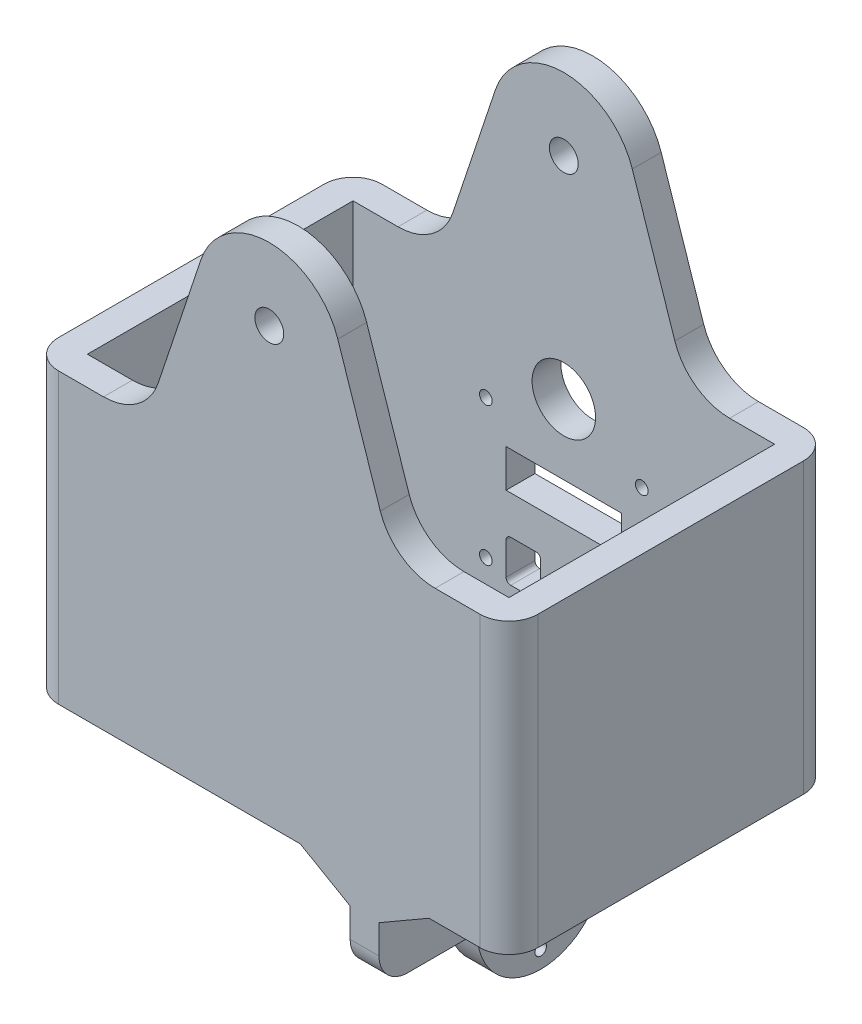
from build123d import *

# Parameters (mm, degrees)
SKETCH3_W             = 32
SKETCH3_H             = 50
BOSS_EXTRUDE1_DEPTH   = 5
CUT_W                 = 20
CUT_H                 = 6.55
CUT_EXTRUDE1_DEPTH    = 10
SKETCH4_W             = 25.5
SKETCH4_H             = 50
BOSS_EXTRUDE2_DEPTH   = 5
SKETCH5_W             = 5
SKETCH5_H             = 50
BOSS_EXTRUDE3_DEPTH   = 51
BOSS_EXTRUDE4_REACH   = 80
SKETCH6_W             = 5
SKETCH6_H             = 50
BOSS_EXTRUDE5_DEPTH   = 5
FILLET1_R             = 10
BOSS_EXTRUDE6_DEPTH   = 5
SKETCH9_W             = 5
SKETCH9_H             = 15
BOSS_EXTRUDE7_DEPTH   = 2.5
BOSS_EXTRUDE8_DEPTH   = 5
SKETCH11_R            = 1
CUT_EXTRUDE2_DEPTH    = 5
FILLET4_R             = 5
FILLET5_R             = 5
CHAMFER1_SIZE         = 5
CHAMFER1_SIZE2        = 8.660254038
CHAMFER1_PART_2_SIZE  = 5
CHAMFER1_PART_2_SIZE2 = 8.660254038
FILLET6_R             = 5
CHAMFER2_SIZE         = 5
CHAMFER2_SIZE2        = 8.660254038
CHAMFER2_PART_2_SIZE  = 5
CHAMFER2_PART_2_SIZE2 = 8.660254038
SKETCH12_R            = 2.5
CUT_EXTRUDE3_DEPTH    = 57


with BuildPart() as part:
    # Sketch3 → Boss-Extrude1 (new body)
    with BuildSketch(Plane(origin=(0, 0, -16), x_dir=(-1, 0, 0), z_dir=(0, 0, -1))):
        with Locations((0, -13.5)):
            Rectangle(SKETCH3_W, SKETCH3_H)
    extrude(amount=BOSS_EXTRUDE1_DEPTH)

    # Cut → Cut-Extrude1 (cut)
    with BuildSketch(Plane(origin=(0, 0, -16), x_dir=(-1, 0, 0), z_dir=(0, 0, -1))):
        with BuildLine():
            Line((9.2, -32.5), (4.8, -32.5))
            ThreePointArc((4.8, -32.5), (4.234314575, -32.265685425), (4, -31.7))
            Line((4, -31.7), (4, -26.1))
            ThreePointArc((4, -26.1), (4.234314575, -25.534314575), (4.8, -25.3))
            Line((4.8, -25.3), (9.2, -25.3))
            ThreePointArc((9.2, -25.3), (9.765685425, -25.534314575), (10, -26.1))
            Line((10, -26.1), (10, -31.7))
            ThreePointArc((10, -31.7), (9.765685425, -32.265685425), (9.2, -32.5))
        make_face()
        with BuildLine():
            Line((-10, -31.7), (-10, -26.1))
            ThreePointArc((-10, -26.1), (-9.765685425, -25.534314575), (-9.2, -25.3))
            Line((-9.2, -25.3), (-4.8, -25.3))
            ThreePointArc((-4.8, -25.3), (-4.234314575, -25.534314575), (-4, -26.1))
            Line((-4, -26.1), (-4, -31.7))
            ThreePointArc((-4, -31.7), (-4.234314575, -32.265685425), (-4.8, -32.5))
            Line((-4.8, -32.5), (-9.2, -32.5))
            ThreePointArc((-9.2, -32.5), (-9.765685425, -32.265685425), (-10, -31.7))
        make_face()
        with Locations((0, -15.375)):
            Rectangle(CUT_W, CUT_H)
        with BuildLine():
            ThreePointArc((-5.5, 0), (0, -5.5), (5.5, 0))
            ThreePointArc((5.5, 0), (0, 5.5), (-5.5, 0))
        make_face()
        with BuildLine():
            ThreePointArc((13.5, -7.6), (14.6, -6.500000002), (13.500000003, -5.4))
            ThreePointArc((13.500000003, -5.4), (12.4, -6.499999998), (13.5, -7.6))
        make_face()
        with BuildLine():
            ThreePointArc((13.5, -31.6), (14.6, -30.500000002), (13.500000003, -29.4))
            ThreePointArc((13.500000003, -29.4), (12.4, -30.499999998), (13.5, -31.6))
        make_face()
        with BuildLine():
            ThreePointArc((-13.5, -31.6), (-12.4, -30.499999998), (-13.500000003, -29.4))
            ThreePointArc((-13.500000003, -29.4), (-14.6, -30.500000002), (-13.5, -31.6))
        make_face()
        with BuildLine():
            ThreePointArc((-13.5, -7.6), (-12.4, -6.499999998), (-13.500000003, -5.4))
            ThreePointArc((-13.500000003, -5.4), (-14.6, -6.500000002), (-13.5, -7.6))
        make_face()
    extrude(amount=CUT_EXTRUDE1_DEPTH, mode=Mode.SUBTRACT)

    # Sketch4 → Boss-Extrude2 (add)
    with BuildSketch(Plane(origin=(0, 0, -21), x_dir=(-1, 0, 0), z_dir=(0, 0, -1))):
        with Locations((-28.75, -13.5)):
            Rectangle(SKETCH4_W, SKETCH4_H)
        with Locations((28.75, -13.5)):
            Rectangle(SKETCH4_W, SKETCH4_H)
    extrude(amount=-BOSS_EXTRUDE2_DEPTH)

    # Sketch5 → Boss-Extrude3 (add)
    with BuildSketch(Plane.XY.offset(-16)):
        with Locations((-39, -13.5)):
            Rectangle(SKETCH5_W, SKETCH5_H)
        with Locations((39, -13.5)):
            Rectangle(SKETCH5_W, SKETCH5_H)
    extrude(amount=BOSS_EXTRUDE3_DEPTH)

    # Sketch6 → Boss-Extrude4 (add, up to next)
    with BuildSketch(Plane.ZY.offset(-36.5), mode=Mode.PRIVATE) as boss_extrude4_sk1:
        with Locations((32.5, -13.5)):
            Rectangle(SKETCH6_W, SKETCH6_H)
    boss_extrude4_tool1 = extrude(boss_extrude4_sk1.sketch, amount=BOSS_EXTRUDE4_REACH, mode=Mode.PRIVATE) - part.part
    add(boss_extrude4_tool1.solids().sort_by_distance((36.5, -13.5, 32.5))[0])

    # Sketch7 → Boss-Extrude5 (add)
    with BuildSketch(Plane(origin=(0, 0, -21), x_dir=(-1, 0, 0), z_dir=(0, 0, -1))):
        with BuildLine():
            Line((-11.859707003, 40.449348023), (-21.5, 11.5))
            Line((-21.5, 11.5), (21.5, 11.5))
            Line((21.5, 11.5), (11.859707003, 40.449348023))
            ThreePointArc((11.859707003, 40.449348023), (0, 49), (-11.859707003, 40.449348023))
        make_face()
    extrude(amount=-BOSS_EXTRUDE5_DEPTH)

    # Fillet1
    fillet1_edges = [part.edges().sort_by_distance(p)[0] for p in [
        (-21.5, 11.5, -18.5),
        (21.5, 11.5, -18.5),
    ]]
    fillet(fillet1_edges, radius=FILLET1_R)

    # Sketch8 → Boss-Extrude6 (add)
    with BuildSketch(Plane.XY.offset(35)):
        with BuildLine():
            Line((11.859707003, 40.449348023), (19.222068481, 18.340521582))
            ThreePointArc((19.222068481, 18.340521582), (22.86153451, 13.388440835), (28.709834084, 11.5))
            Line((28.709834084, 11.5), (-28.709834084, 11.5))
            ThreePointArc((-28.709834084, 11.5), (-22.86153451, 13.388440835), (-19.222068481, 18.340521582))
            Line((-19.222068481, 18.340521582), (-11.859707003, 40.449348023))
            ThreePointArc((-11.859707003, 40.449348023), (0, 49), (11.859707003, 40.449348023))
        make_face()
    extrude(amount=-BOSS_EXTRUDE6_DEPTH)

    # Sketch9 → Boss-Extrude7 (add, symmetric)
    with BuildSketch(Plane(origin=(16.5, 0, 0), x_dir=(0, 0, -1), z_dir=(1, 0, 0))):
        with Locations((-32.5, -46)):
            Rectangle(SKETCH9_W, SKETCH9_H)
        with Locations((18.5, -46)):
            Rectangle(SKETCH9_W, SKETCH9_H)
    extrude(amount=BOSS_EXTRUDE7_DEPTH, both=True)

    # Sketch10 → Boss-Extrude8 (add)
    with BuildSketch(Plane(origin=(19, 0, 0), x_dir=(0, 0, -1), z_dir=(1, 0, 0))):
        with BuildLine():
            Line((-30, -53.5), (-18, -53.5))
            ThreePointArc((-18, -53.5), (-7, -64.5), (4, -53.5))
            Line((4, -53.5), (16, -53.5))
            Line((16, -53.5), (16, -43.5))
            Line((16, -43.5), (-2.417424305, -43.5))
            ThreePointArc((-2.417424305, -43.5), (-7, -42.5), (-11.582575695, -43.5))
            Line((-11.582575695, -43.5), (-30, -43.5))
            Line((-30, -43.5), (-30, -53.5))
        make_face()
    extrude(amount=-BOSS_EXTRUDE8_DEPTH)

    # Sketch11 → Cut-Extrude2 (cut)
    with BuildSketch(Plane(origin=(19, 0, 0), x_dir=(0, 0, -1), z_dir=(1, 0, 0))):
        with Locations((-15, -53.5)):
            Circle(SKETCH11_R)
        with Locations((-7, -45.5)):
            Circle(SKETCH11_R)
        with Locations((1, -53.5)):
            Circle(SKETCH11_R)
        with Locations((-7, -61.5)):
            Circle(SKETCH11_R)
    extrude(amount=-CUT_EXTRUDE2_DEPTH, mode=Mode.SUBTRACT)

    # Fillet4
    fillet4_edges = [part.edges().sort_by_distance(p)[0] for p in [
        (41.5, -13.5, -21),
        (-41.5, -13.5, -21),
        (-41.5, -13.5, 35),
        (41.5, -13.5, 35),
    ]]
    fillet(fillet4_edges, radius=FILLET4_R)

    # Fillet5
    fillet5_edges = [part.edges().sort_by_distance(p)[0] for p in [
        (16.5, -53.5, 35),
        (16.5, -53.5, -21),
    ]]
    fillet(fillet5_edges, radius=FILLET5_R)

    # Chamfer1
    chamfer1_edges = [part.edges().sort_by_distance(p)[0] for p in [
        (16.5, -43.5, -16),
    ]]
    chamfer1_side = [part.faces().sort_by_distance(p)[0] for p in [
        (-22.17239609, 12.432609658, -16),
    ]]
    chamfer(chamfer1_edges, length=CHAMFER1_SIZE, length2=CHAMFER1_SIZE2, reference=chamfer1_side[0])

    # Chamfer1 part 2
    chamfer1_part_2_edges = [part.edges().sort_by_distance(p)[0] for p in [
        (16.5, -43.5, 30),
    ]]
    chamfer1_part_2_side = [part.faces().sort_by_distance(p)[0] for p in [
        (0.085787805, -4.114556323, 30),
    ]]
    chamfer(chamfer1_part_2_edges, length=CHAMFER1_PART_2_SIZE, length2=CHAMFER1_PART_2_SIZE2, reference=chamfer1_part_2_side[0])

    # Fillet6
    fillet6_edges = [part.edges().sort_by_distance(p)[0] for p in [
        (16.5, -38.5, -16),
        (16.5, -38.5, 30),
    ]]
    fillet(fillet6_edges, radius=FILLET6_R)

    # Chamfer2
    chamfer2_edges = [part.edges().sort_by_distance(p)[0] for p in [
        (14, -38.5, 32.5),
        (14, -38.5, -18.5),
    ]]
    chamfer2_side = [part.faces().sort_by_distance(p)[0] for p in [
        (14, -49.7166158, 7),
    ]]
    chamfer(chamfer2_edges, length=CHAMFER2_SIZE, length2=CHAMFER2_SIZE2, reference=chamfer2_side[0])

    # Chamfer2 part 2
    chamfer2_part_2_edges = [part.edges().sort_by_distance(p)[0] for p in [
        (19, -38.5, 32.5),
        (19, -38.5, -18.5),
    ]]
    chamfer2_part_2_side = [part.faces().sort_by_distance(p)[0] for p in [
        (19, -49.7166158, 7),
    ]]
    chamfer(chamfer2_part_2_edges, length=CHAMFER2_PART_2_SIZE, length2=CHAMFER2_PART_2_SIZE2, reference=chamfer2_part_2_side[0])

    # Sketch12 → Cut-Extrude3 (cut, through all)
    with BuildSketch(Plane.XY.offset(35)):
        with Locations((0, 36.5)):
            Circle(SKETCH12_R)
    extrude(amount=-CUT_EXTRUDE3_DEPTH, mode=Mode.SUBTRACT)


solid = part.part
